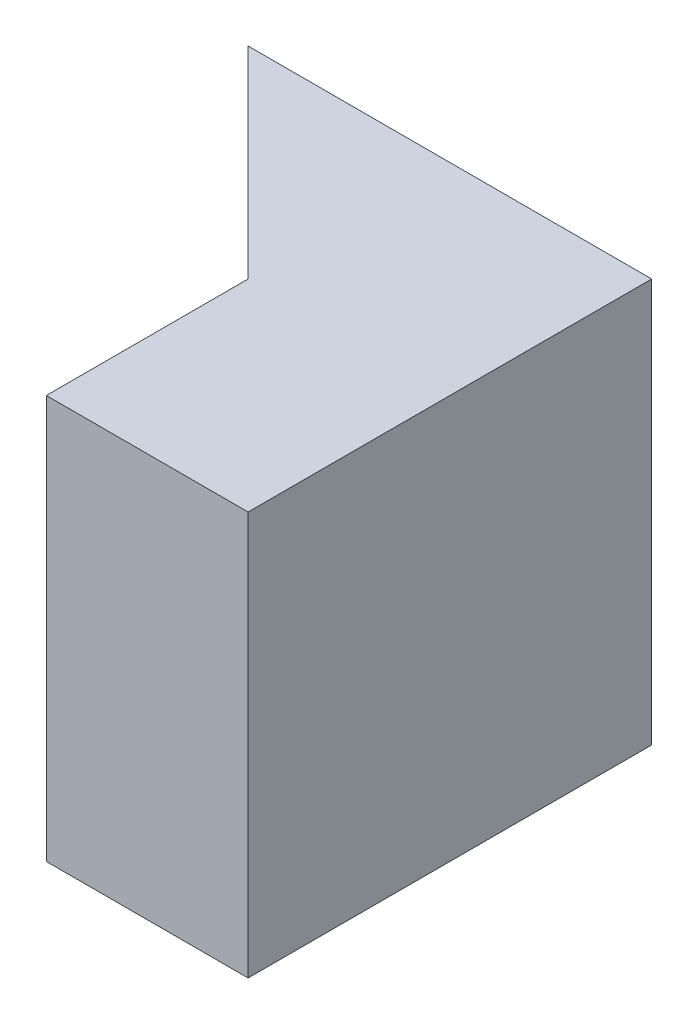
from build123d import *

# Parameters (mm, degrees)
SKETCH1_W           = 20
SKETCH1_H           = 20
BOSS_EXTRUDE1_DEPTH = 20
SKETCH2_W           = 10
SKETCH2_H           = 10
CUT_EXTRUDE1_DEPTH  = 20
CUT_EXTRUDE2_DEPTH  = 20


with BuildPart() as part:
    # Sketch1 → Boss-Extrude1 (new body)
    with BuildSketch(Plane.XY):
        with Locations((10, 10)):
            Rectangle(SKETCH1_W, SKETCH1_H)
    extrude(amount=BOSS_EXTRUDE1_DEPTH)

    # Sketch2 → Cut-Extrude1 (cut)
    with BuildSketch(Plane(origin=(0, 20, 0), x_dir=(1, 0, 0), z_dir=(0, 1, 0))):
        with Locations((5, -15)):
            Rectangle(SKETCH2_W, SKETCH2_H)
    extrude(amount=-CUT_EXTRUDE1_DEPTH, mode=Mode.SUBTRACT)

    # Sketch3 → Cut-Extrude2 (cut)
    with BuildSketch(Plane(origin=(0, 20, 0), x_dir=(1, 0, 0), z_dir=(0, 1, 0))):
        Polygon((0, 0), (10, -10), (0, -10), align=None)
    extrude(amount=-CUT_EXTRUDE2_DEPTH, mode=Mode.SUBTRACT)


solid = part.part
